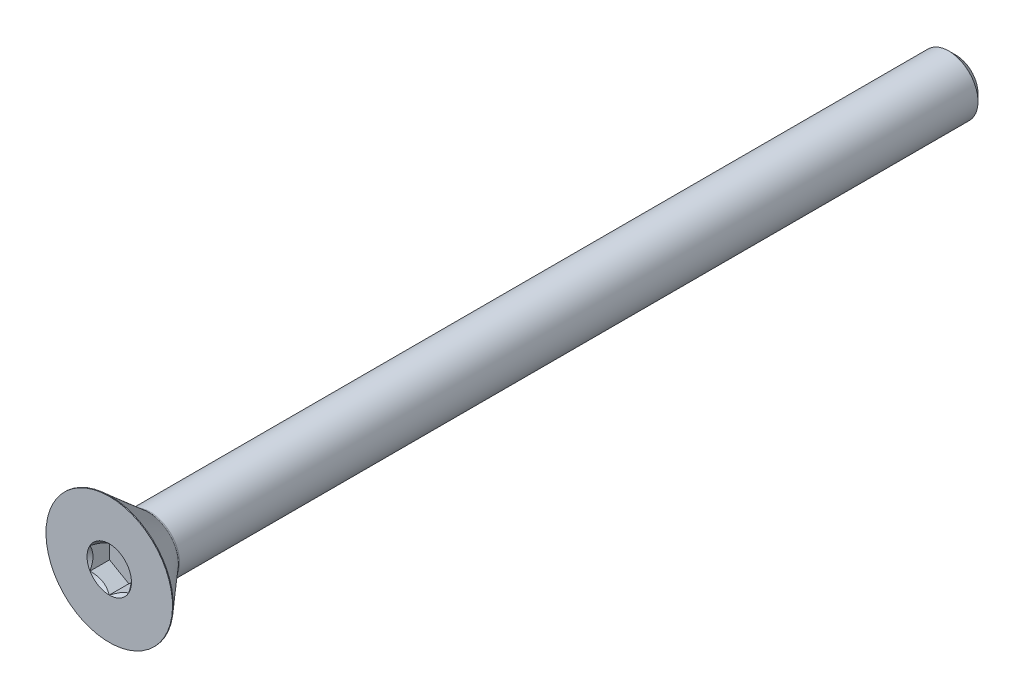
from build123d import *

# Parameters (mm, degrees)
SKETCH10_R         = 1.833087105
CUT_EXTRUDE2_DEPTH = 1.6129
CUT_EXTRUDE2_TAPER = 45
CUT_EXTRUDE1_DEPTH = 1.6129


with BuildPart() as part:
    # Sketch2 → Revolve1 (revolve)
    with BuildSketch(Plane(origin=(0, 0, 0), x_dir=(0, 0, -1), z_dir=(1, 0, 0))):
        with BuildLine():
            Line((-34.860484, 5.2197), (-31.6992, 2.471637744))
            ThreePointArc((-31.6992, 2.471637744), (-31.62608483, 2.428138789), (-31.542366229, 2.413))
            Line((-31.542366229, 2.413), (34.3296875, 2.413))
            Line((34.3296875, 2.413), (34.925, 1.8176875))
            Line((34.925, 1.8176875), (34.925, 0))
            Line((34.925, 0), (-34.925, 0))
            Line((-34.925, 0), (-34.925, 5.2197))
            Line((-34.925, 5.2197), (-34.860484, 5.2197))
        make_face()
    revolve(axis=Axis((0, 0, -34.925), (0, 0, 1)))

    # Sketch10 → Cut-Extrude2 (cut)
    with BuildSketch(Plane.XY.offset(34.925)):
        Circle(SKETCH10_R)
    extrude(amount=-CUT_EXTRUDE2_DEPTH, taper=CUT_EXTRUDE2_TAPER, mode=Mode.SUBTRACT)

    # Sketch9 → Cut-Extrude1 (cut)
    with BuildSketch(Plane.XY.offset(34.925)):
        Polygon((1.5875, -0.916543552), (1.5875, 0.916543552), (0, 1.833087105), (-1.5875, 0.916543552), (-1.5875, -0.916543552), (0, -1.833087105), align=None)
    extrude(amount=-CUT_EXTRUDE1_DEPTH, mode=Mode.SUBTRACT)


solid = part.part
